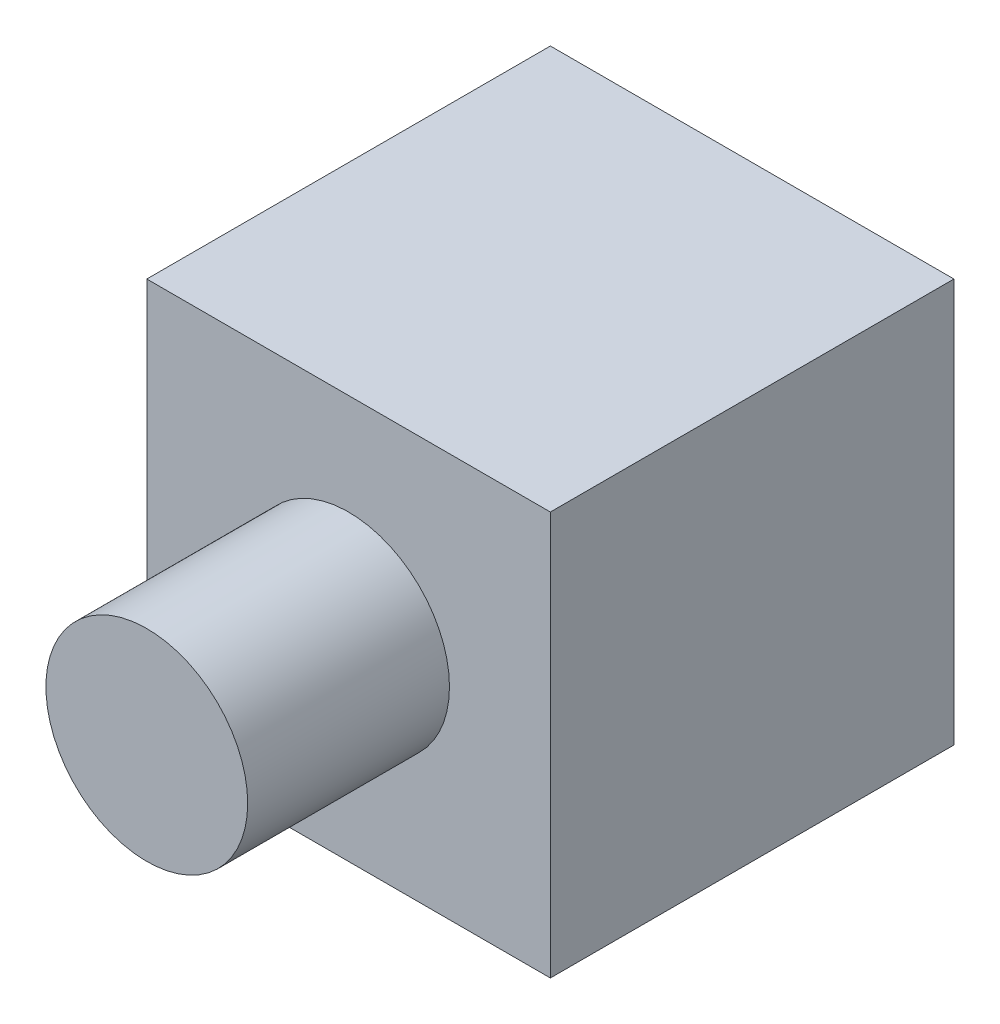
from build123d import *

# Parameters (mm, degrees)
BOSS_EXTRUDE1_DEPTH      = 50
BOSS_EXTRUDE1_DEPTH_BACK = 50
SKETCH1_W                = 100
SKETCH1_H                = 100
SKETCH2_R                = 25
BOSS_EXTRUDE2_DEPTH      = 60


with BuildPart() as part:
    # Sketch1 → Boss-Extrude1 (new, two sides: drawn at the far end of the back side and taken through both)
    with BuildSketch(Plane.XY.offset(-BOSS_EXTRUDE1_DEPTH_BACK)):
        Rectangle(SKETCH1_W, SKETCH1_H)
    extrude(amount=BOSS_EXTRUDE1_DEPTH + BOSS_EXTRUDE1_DEPTH_BACK)

    # Sketch2 → Boss-Extrude2 (add)
    with BuildSketch(Plane.XY.offset(100)):
        Circle(SKETCH2_R)
    extrude(amount=-BOSS_EXTRUDE2_DEPTH)


solid = part.part
